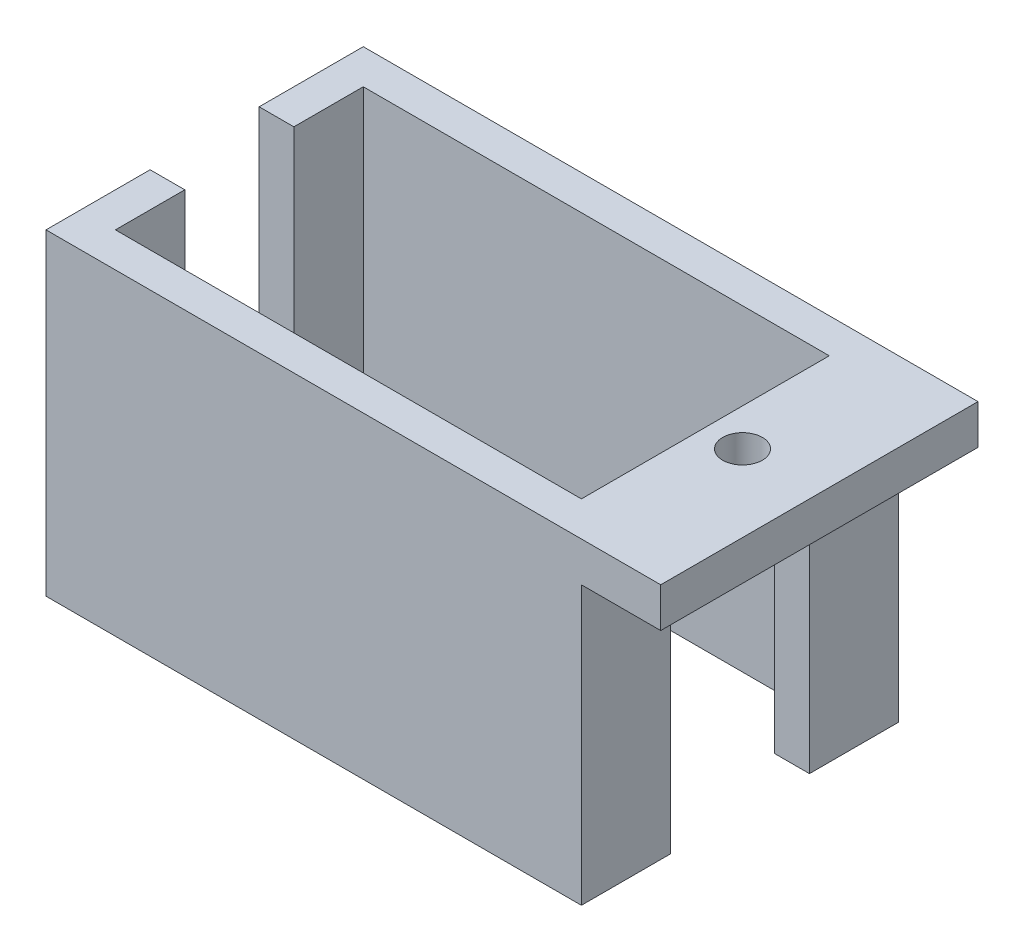
from build123d import *

# Parameters (mm, degrees)
SKETCH1_W           = 27
SKETCH1_H           = 16
BOSS_EXTRUDE1_DEPTH = 16
SKETCH2_W           = 23.5
SKETCH2_H           = 12.5
CUT_EXTRUDE1_DEPTH  = 16
SKETCH3_W           = 5.5
SKETCH3_H           = 13
CUT_EXTRUDE2_DEPTH  = 4
SKETCH4_W           = 16
SKETCH4_H           = 2
BOSS_EXTRUDE2_DEPTH = 4
SKETCH5_R           = 1
CUT_EXTRUDE3_DEPTH  = 17
SKETCH6_W           = 7
SKETCH6_H           = 14
CUT_EXTRUDE4_DEPTH  = 4


with BuildPart() as part:
    # Sketch1 → Boss-Extrude1 (new body)
    with BuildSketch(Plane(origin=(0, 0, 0), x_dir=(1, 0, 0), z_dir=(0, 1, 0))):
        Rectangle(SKETCH1_W, SKETCH1_H)
    extrude(amount=BOSS_EXTRUDE1_DEPTH)

    # Sketch2 → Cut-Extrude1 (cut)
    with BuildSketch(Plane(origin=(0, 16, 0), x_dir=(1, 0, 0), z_dir=(0, 1, 0))):
        Rectangle(SKETCH2_W, SKETCH2_H)
    extrude(amount=-CUT_EXTRUDE1_DEPTH, mode=Mode.SUBTRACT)

    # Sketch3 → Cut-Extrude2 (cut)
    with BuildSketch(Plane.ZY.offset(13.5)):
        with Locations((0, 9.5)):
            Rectangle(SKETCH3_W, SKETCH3_H)
    extrude(amount=-CUT_EXTRUDE2_DEPTH, mode=Mode.SUBTRACT)

    # Sketch4 → Boss-Extrude2 (add)
    with BuildSketch(Plane(origin=(13.5, 0, 0), x_dir=(0, 0, -1), z_dir=(1, 0, 0))):
        with Locations((0, 15)):
            Rectangle(SKETCH4_W, SKETCH4_H)
    extrude(amount=BOSS_EXTRUDE2_DEPTH)

    # Sketch5 → Cut-Extrude3 (cut, through all)
    with BuildSketch(Plane(origin=(0, 16, 0), x_dir=(1, 0, 0), z_dir=(0, 1, 0))):
        with Locations((13.625, 0)):
            Circle(SKETCH5_R)
    extrude(amount=-CUT_EXTRUDE3_DEPTH, mode=Mode.SUBTRACT)

    # Sketch6 → Cut-Extrude4 (cut)
    with BuildSketch(Plane(origin=(13.5, 0, 0), x_dir=(0, 0, -1), z_dir=(1, 0, 0))):
        with Locations((0, 7)):
            Rectangle(SKETCH6_W, SKETCH6_H)
    extrude(amount=-CUT_EXTRUDE4_DEPTH, mode=Mode.SUBTRACT)


solid = part.part
